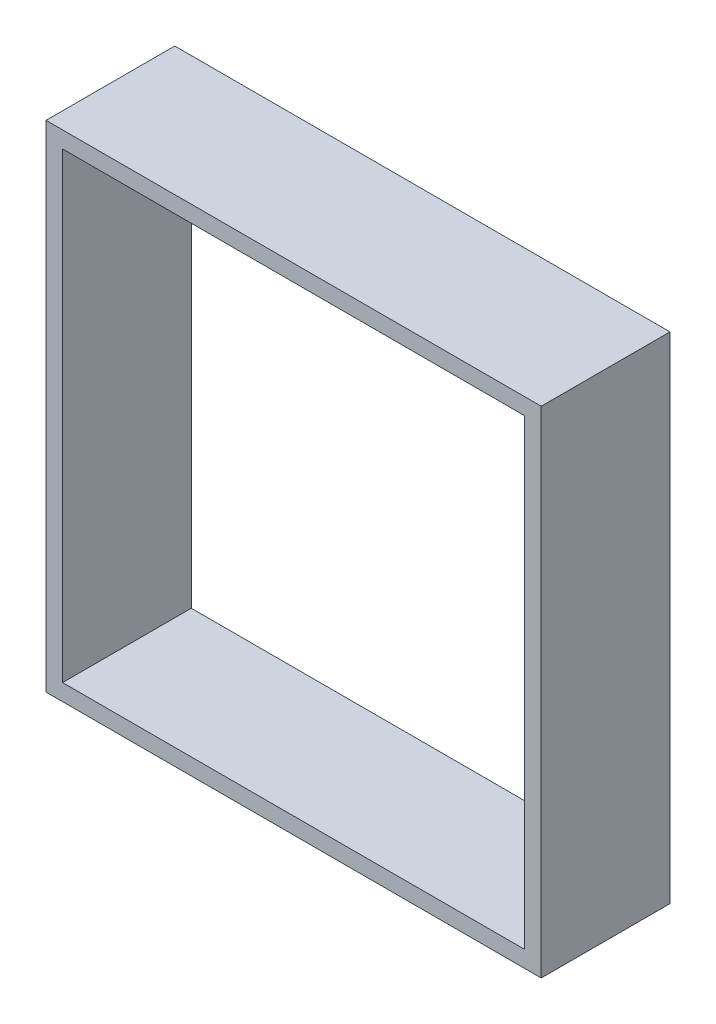
from build123d import *

# Parameters (mm, degrees)
ESQUISSE1_W        = 30
ESQUISSE1_H        = 30
ESQUISSE1_W_2      = 28
ESQUISSE1_H_2      = 28
BOSS_EXTRU_1_DEPTH = 7.8


with BuildPart() as part:
    # Esquisse1 → Boss.-Extru.1 (new body)
    with BuildSketch(Plane.XY):
        Rectangle(ESQUISSE1_W, ESQUISSE1_H)
        Rectangle(ESQUISSE1_W_2, ESQUISSE1_H_2, mode=Mode.SUBTRACT)
    extrude(amount=BOSS_EXTRU_1_DEPTH)


solid = part.part
